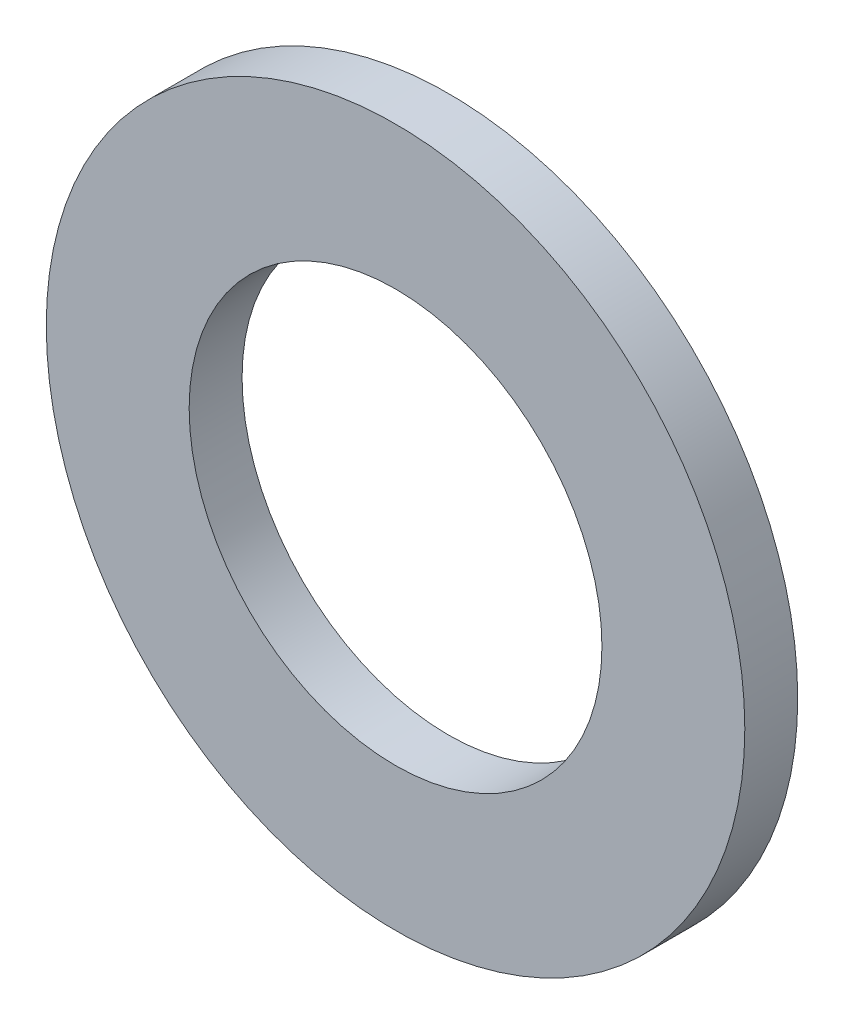
from build123d import *

# Parameters (mm, degrees)
SKETCH_1_R      = 33
SKETCH_1_R_2    = 19.5
EXTRUDE_1_DEPTH = 5


with BuildPart() as part:
    # Эскиз1 → Бобышка-Вытянуть1 (new body)
    with BuildSketch(Plane.XY):
        Circle(SKETCH_1_R)
        Circle(SKETCH_1_R_2, mode=Mode.SUBTRACT)
    extrude(amount=EXTRUDE_1_DEPTH)


solid = part.part
